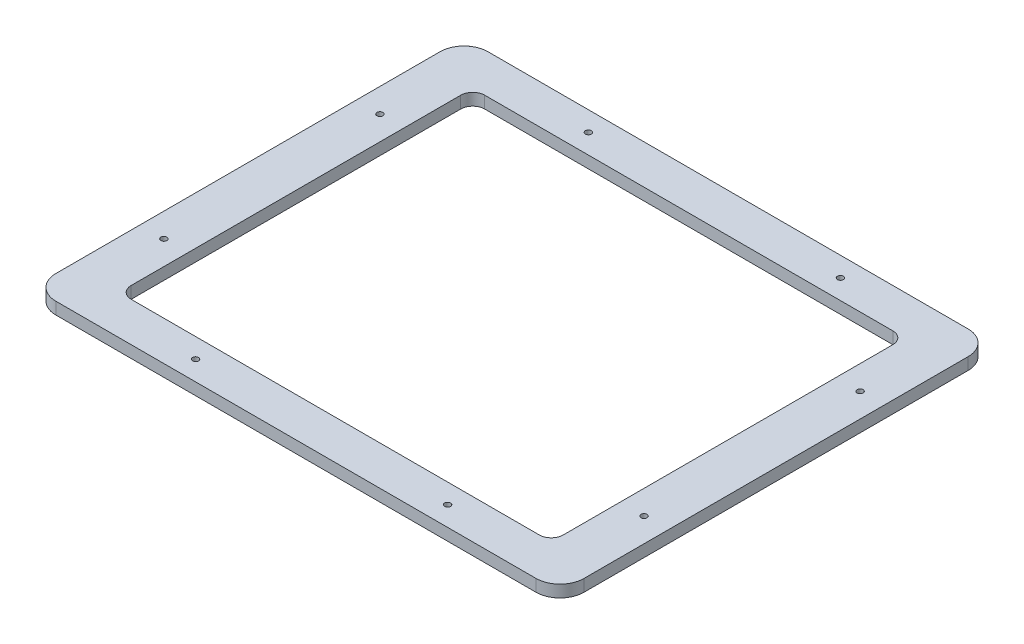
from build123d import *

# Parameters (mm, degrees)
SKETCH1_W           = 279.4
SKETCH1_H           = 228.6
SKETCH1_W_2         = 228.6
SKETCH1_H_2         = 187.036363636
BOSS_EXTRUDE1_DEPTH = 6.35
SKETCH2_R           = 1.5875
CUT_EXTRUDE1_DEPTH  = 7.35
FILLET1_R           = 12.7
FILLET2_R           = 6.35


with BuildPart() as part:
    # Sketch1 → Boss-Extrude1 (new body)
    with BuildSketch(Plane(origin=(0, 0, 0), x_dir=(1, 0, 0), z_dir=(0, 1, 0))):
        Rectangle(SKETCH1_W, SKETCH1_H)
        Rectangle(SKETCH1_W_2, SKETCH1_H_2, mode=Mode.SUBTRACT)
    extrude(amount=BOSS_EXTRUDE1_DEPTH)

    # Sketch2 → Cut-Extrude1 (cut, through all)
    with BuildSketch(Plane(origin=(0, 6.35, 0), x_dir=(1, 0, 0), z_dir=(0, 1, 0))):
        with Locations((-63.5, 103.909090909)):
            Circle(SKETCH2_R)
        with Locations((-63.5, -103.909090909)):
            Circle(SKETCH2_R)
        with Locations((69.85, 103.909090909)):
            Circle(SKETCH2_R)
        with Locations((69.85, -103.909090909)):
            Circle(SKETCH2_R)
        with Locations((-127, 57.15)):
            Circle(SKETCH2_R)
        with Locations((-127, -57.15)):
            Circle(SKETCH2_R)
        with Locations((127, 57.15)):
            Circle(SKETCH2_R)
        with Locations((127, -57.15)):
            Circle(SKETCH2_R)
    extrude(amount=-CUT_EXTRUDE1_DEPTH, mode=Mode.SUBTRACT)

    # Fillet1
    fillet1_edges = [part.edges().sort_by_distance(p)[0] for p in [
        (139.7, 3.175, 114.3),
        (-139.7, 3.175, 114.3),
        (-139.7, 3.175, -114.3),
        (139.7, 3.175, -114.3),
    ]]
    fillet(fillet1_edges, radius=FILLET1_R)

    # Fillet2
    fillet2_edges = [part.edges().sort_by_distance(p)[0] for p in [
        (114.3, 3.175, 93.518181818),
        (114.3, 3.175, -93.518181818),
        (-114.3, 3.175, -93.518181818),
        (-114.3, 3.175, 93.518181818),
    ]]
    fillet(fillet2_edges, radius=FILLET2_R)


solid = part.part
